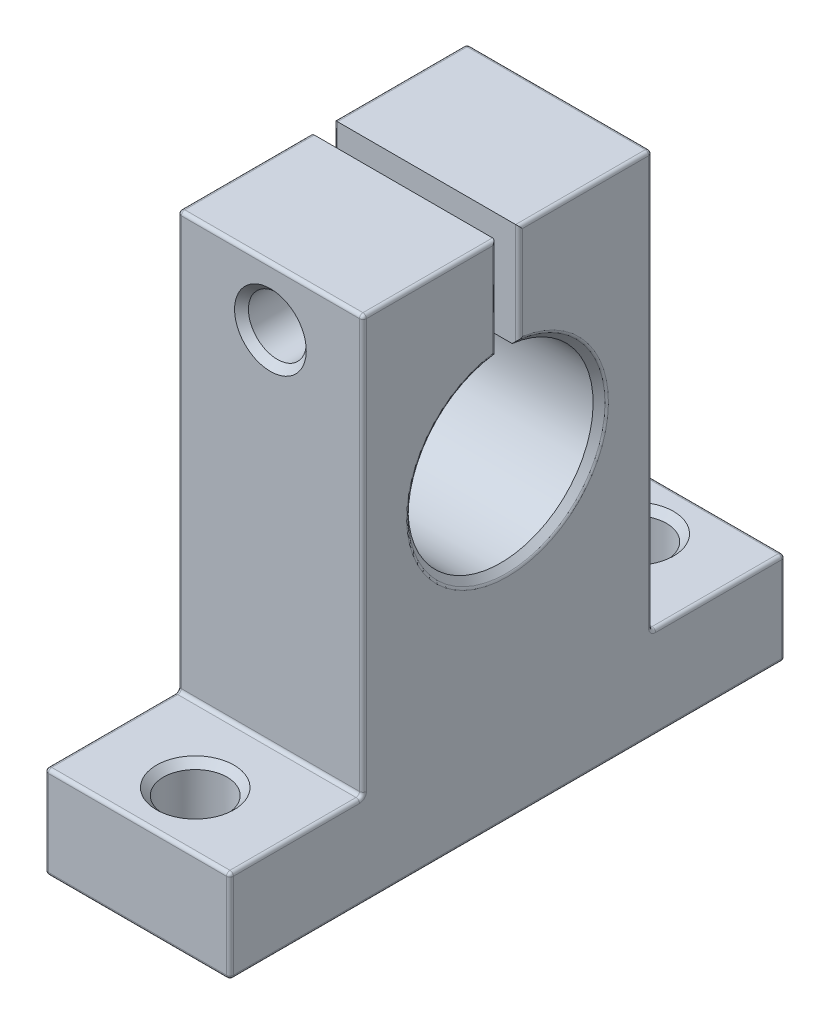
from build123d import *

# Parameters (mm, degrees)
BOSS_EXTRUDE1_DEPTH = 8
SKETCH2_R           = 2.75
CUT_EXTRUDE1_DEPTH  = 9
SKETCH3_R           = 2.5
CUT_EXTRUDE2_DEPTH  = 37.5
SKETCH4_R           = 4
CUT_EXTRUDE3_DEPTH  = 5
CHAMFER_1_SIZE      = 0.6
FILLET_1_R          = 0.3


with BuildPart() as part:
    # Sketch1 → Boss-Extrude1 (new body, symmetric)
    with BuildSketch(Plane(origin=(0, 0, 0), x_dir=(0, 0, -1), z_dir=(1, 0, 0))):
        with BuildLine():
            Line((-24, 0), (24, 0))
            Line((24, 0), (24, 8))
            Line((24, 8), (12.5, 8))
            Line((12.5, 8), (12.5, 44))
            Line((12.5, 44), (1, 44))
            Line((1, 44), (1, 34.937253933))
            ThreePointArc((1, 34.937253933), (0, 19), (-1, 34.937253933))
            Line((-1, 34.937253933), (-1, 44))
            Line((-1, 44), (-12.5, 44))
            Line((-12.5, 44), (-12.5, 8))
            Line((-12.5, 8), (-24, 8))
            Line((-24, 8), (-24, 0))
        make_face()
    extrude(amount=BOSS_EXTRUDE1_DEPTH, both=True)

    # Sketch2 → Cut-Extrude1 (cut, through all)
    with BuildSketch(Plane(origin=(0, 8, 0), x_dir=(1, 0, 0), z_dir=(0, 1, 0))):
        with Locations(Location((0, -19, 0), (0, 0, 270))):  # turned: the seam where the file's is
            Circle(SKETCH2_R)
        with Locations(Location((0, 19, 0), (0, 0, 270))):  # turned: the seam where the file's is
            Circle(SKETCH2_R)
    extrude(amount=-CUT_EXTRUDE1_DEPTH, mode=Mode.SUBTRACT)

    # Sketch3 → Cut-Extrude2 (cut, through all)
    with BuildSketch(Plane(origin=(0, 0, -12.5), x_dir=(-1, 0, 0), z_dir=(0, 0, -1))):
        with Locations(Location((0, 39, 0), (0, 0, 90))):  # turned: the seam where the file's is
            Circle(SKETCH3_R)
    extrude(amount=-CUT_EXTRUDE2_DEPTH, mode=Mode.SUBTRACT)

    # Sketch4 → Cut-Extrude3 (cut)
    with BuildSketch(Plane(origin=(0, 0, -12.5), x_dir=(-1, 0, 0), z_dir=(0, 0, -1))):
        with Locations((0, 39)):
            Circle(SKETCH4_R)
    extrude(amount=-CUT_EXTRUDE3_DEPTH, mode=Mode.SUBTRACT)

    # Фаска1
    chamfer_1_edges = [part.edges().sort_by_distance(p)[0] for p in [
        (8, 19, 0),
        (0, 0, 16.25),
        (0, 8, 16.25),
        (0, 0, -21.75),
        (0, 8, -21.75),
        (0, 36.5, 12.5),
        (4, 39, -12.5),
    ]]
    chamfer(chamfer_1_edges, length=CHAMFER_1_SIZE)

    # Скругление1
    fillet_1_edges = [part.edges().sort_by_distance(p)[0] for p in [
        (-8, 0, 0),
        (-8, 4, -24),
        (-8, 8, -18.25),
        (-8, 26, -12.5),
        (-8, 44, -6.75),
        (-8, 39.468626967, -1),
        (-8, 19, 0),
        (-8, 39.468626967, 1),
        (-8, 44, 6.75),
        (-8, 26, 12.5),
        (-8, 8, 18.25),
        (-8, 4, 24),
        (8, 44, -6.75),
        (8, 26, -12.5),
        (8, 8, -18.25),
        (8, 4, -24),
        (8, 0, 0),
        (8, 4, 24),
        (8, 8, 18.25),
        (8, 26, 12.5),
        (8, 44, 6.75),
        (8, 39.770831301, 1),
        (8, 18.4, 0),
        (8, 39.770831301, -1),
        (0, 0, -24),
        (0, 8, -24),
        (0, 8, -12.5),
        (0, 44, -12.5),
        (0, 0, 24),
        (0, 44, 12.5),
        (0, 8, 12.5),
        (0, 8, 24),
    ]]
    fillet(fillet_1_edges, radius=FILLET_1_R)


solid = part.part
